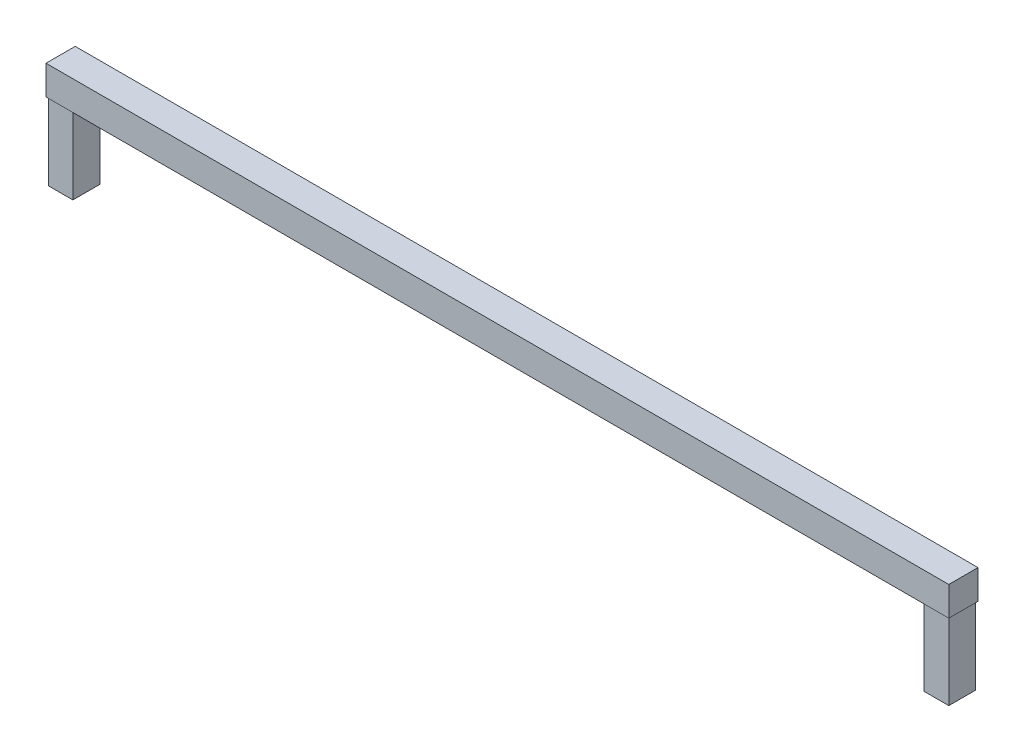
from build123d import *

# Parameters (mm, degrees)
SKETCH2_W           = 587
SKETCH2_H           = 38
EXTRUDE_THIN1_DEPTH = 38
SKETCH3_W           = 31.95
SKETCH3_H           = 35
BOSS_EXTRUDE1_DEPTH = 100


with BuildPart() as part:
    # Sketch2 → Extrude-Thin1 (new body)
    with BuildSketch(Plane.XY):
        with Locations((-293.5, 19)):
            Rectangle(SKETCH2_W, SKETCH2_H)
    extrude(amount=EXTRUDE_THIN1_DEPTH)

    # Sketch3 → Boss-Extrude1 (add)
    with BuildSketch(Plane.XZ):
        with Locations((-569.525, 19)):
            Rectangle(SKETCH3_W, SKETCH3_H)
    extrude(amount=BOSS_EXTRUDE1_DEPTH)

    # Mirror1: part across plane


with BuildPart() as part_1:
    add(part.part)
    add(part.part.mirror(Plane(origin=(0, 38, 38), x_dir=(0, 0, 1), z_dir=(1, 0, 0))))


solid = part_1.part
